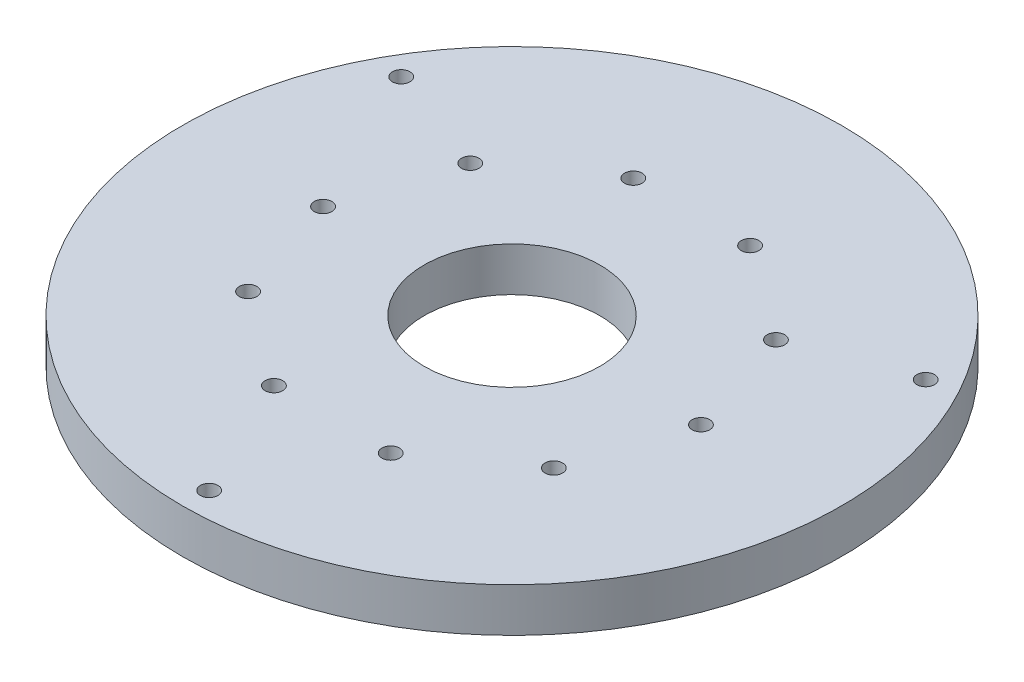
from build123d import *

# Parameters (mm, degrees)
SKETCH1_R           = 37.5
BOSS_EXTRUDE1_DEPTH = 5
CUT_EXTRUDE1_REACH  = 7
SKETCH2_R           = 1
CUT_EXTRUDE2_DEPTH  = 1.6
CUT_EXTRUDE3_REACH  = 7
SKETCH6_R           = 10
SKETCH7_R           = 1
CUT_EXTRUDE4_DEPTH  = 5


with BuildPart() as part:
    # Sketch1 → Boss-Extrude1 (new body)
    with BuildSketch(Plane(origin=(0, 0, 0), x_dir=(1, 0, 0), z_dir=(0, 1, 0))):
        Circle(SKETCH1_R)
    extrude(amount=-BOSS_EXTRUDE1_DEPTH)

    # Sketch2 → Cut-Extrude1 (cut, up to next)
    with BuildSketch(Plane(origin=(0, 0, 0), x_dir=(1, 0, 0), z_dir=(0, 1, 0)), mode=Mode.PRIVATE) as cut_extrude1_sk1:
        with Locations((-21.5, 0)):
            Circle(SKETCH2_R)
    cut_extrude1_tool1 = extrude(cut_extrude1_sk1.sketch, amount=-CUT_EXTRUDE1_REACH, mode=Mode.PRIVATE) & part.part
    add(cut_extrude1_tool1.solids().sort_by_distance((-21.5, 0, 0))[0], mode=Mode.SUBTRACT)
    # Sketch2 → Cut-Extrude1 (cut, up to next)
    with BuildSketch(Plane(origin=(0, 0, 0), x_dir=(1, 0, 0), z_dir=(0, 1, 0)), mode=Mode.PRIVATE) as cut_extrude1_sk2:
        with Locations((-17.393865379, 12.637382924)):
            Circle(SKETCH2_R)
    cut_extrude1_tool2 = extrude(cut_extrude1_sk2.sketch, amount=-CUT_EXTRUDE1_REACH, mode=Mode.PRIVATE) & part.part
    add(cut_extrude1_tool2.solids().sort_by_distance((-17.393865, 0, -12.637383))[0], mode=Mode.SUBTRACT)
    # Sketch2 → Cut-Extrude1 (cut, up to next)
    with BuildSketch(Plane(origin=(0, 0, 0), x_dir=(1, 0, 0), z_dir=(0, 1, 0)), mode=Mode.PRIVATE) as cut_extrude1_sk3:
        with Locations((-6.643865379, 20.4477151)):
            Circle(SKETCH2_R)
    cut_extrude1_tool3 = extrude(cut_extrude1_sk3.sketch, amount=-CUT_EXTRUDE1_REACH, mode=Mode.PRIVATE) & part.part
    add(cut_extrude1_tool3.solids().sort_by_distance((-6.643865, 0, -20.447715))[0], mode=Mode.SUBTRACT)
    # Sketch2 → Cut-Extrude1 (cut, up to next)
    with BuildSketch(Plane(origin=(0, 0, 0), x_dir=(1, 0, 0), z_dir=(0, 1, 0)), mode=Mode.PRIVATE) as cut_extrude1_sk4:
        with Locations((6.643865379, 20.4477151)):
            Circle(SKETCH2_R)
    cut_extrude1_tool4 = extrude(cut_extrude1_sk4.sketch, amount=-CUT_EXTRUDE1_REACH, mode=Mode.PRIVATE) & part.part
    add(cut_extrude1_tool4.solids().sort_by_distance((6.643865, 0, -20.447715))[0], mode=Mode.SUBTRACT)
    # Sketch2 → Cut-Extrude1 (cut, up to next)
    with BuildSketch(Plane(origin=(0, 0, 0), x_dir=(1, 0, 0), z_dir=(0, 1, 0)), mode=Mode.PRIVATE) as cut_extrude1_sk5:
        with Locations((17.393865379, 12.637382924)):
            Circle(SKETCH2_R)
    cut_extrude1_tool5 = extrude(cut_extrude1_sk5.sketch, amount=-CUT_EXTRUDE1_REACH, mode=Mode.PRIVATE) & part.part
    add(cut_extrude1_tool5.solids().sort_by_distance((17.393865, 0, -12.637383))[0], mode=Mode.SUBTRACT)
    # Sketch2 → Cut-Extrude1 (cut, up to next)
    with BuildSketch(Plane(origin=(0, 0, 0), x_dir=(1, 0, 0), z_dir=(0, 1, 0)), mode=Mode.PRIVATE) as cut_extrude1_sk6:
        with Locations((21.5, 0)):
            Circle(SKETCH2_R)
    cut_extrude1_tool6 = extrude(cut_extrude1_sk6.sketch, amount=-CUT_EXTRUDE1_REACH, mode=Mode.PRIVATE) & part.part
    add(cut_extrude1_tool6.solids().sort_by_distance((21.5, 0, 0))[0], mode=Mode.SUBTRACT)
    # Sketch2 → Cut-Extrude1 (cut, up to next)
    with BuildSketch(Plane(origin=(0, 0, 0), x_dir=(1, 0, 0), z_dir=(0, 1, 0)), mode=Mode.PRIVATE) as cut_extrude1_sk7:
        with Locations((17.393865379, -12.637382924)):
            Circle(SKETCH2_R)
    cut_extrude1_tool7 = extrude(cut_extrude1_sk7.sketch, amount=-CUT_EXTRUDE1_REACH, mode=Mode.PRIVATE) & part.part
    add(cut_extrude1_tool7.solids().sort_by_distance((17.393865, 0, 12.637383))[0], mode=Mode.SUBTRACT)
    # Sketch2 → Cut-Extrude1 (cut, up to next)
    with BuildSketch(Plane(origin=(0, 0, 0), x_dir=(1, 0, 0), z_dir=(0, 1, 0)), mode=Mode.PRIVATE) as cut_extrude1_sk8:
        with Locations((6.643865379, -20.4477151)):
            Circle(SKETCH2_R)
    cut_extrude1_tool8 = extrude(cut_extrude1_sk8.sketch, amount=-CUT_EXTRUDE1_REACH, mode=Mode.PRIVATE) & part.part
    add(cut_extrude1_tool8.solids().sort_by_distance((6.643865, 0, 20.447715))[0], mode=Mode.SUBTRACT)
    # Sketch2 → Cut-Extrude1 (cut, up to next)
    with BuildSketch(Plane(origin=(0, 0, 0), x_dir=(1, 0, 0), z_dir=(0, 1, 0)), mode=Mode.PRIVATE) as cut_extrude1_sk9:
        with Locations((-6.643865379, -20.4477151)):
            Circle(SKETCH2_R)
    cut_extrude1_tool9 = extrude(cut_extrude1_sk9.sketch, amount=-CUT_EXTRUDE1_REACH, mode=Mode.PRIVATE) & part.part
    add(cut_extrude1_tool9.solids().sort_by_distance((-6.643865, 0, 20.447715))[0], mode=Mode.SUBTRACT)
    # Sketch2 → Cut-Extrude1 (cut, up to next)
    with BuildSketch(Plane(origin=(0, 0, 0), x_dir=(1, 0, 0), z_dir=(0, 1, 0)), mode=Mode.PRIVATE) as cut_extrude1_sk10:
        with Locations((-17.393865379, -12.637382924)):
            Circle(SKETCH2_R)
    cut_extrude1_tool10 = extrude(cut_extrude1_sk10.sketch, amount=-CUT_EXTRUDE1_REACH, mode=Mode.PRIVATE) & part.part
    add(cut_extrude1_tool10.solids().sort_by_distance((-17.393865, 0, 12.637383))[0], mode=Mode.SUBTRACT)

    # Sketch4 → Cut-Extrude2 (cut)
    with BuildSketch(Plane.XZ.offset(5)):
        Polygon((-15.525520661, 11.27995103), (-15.284122516, 13.576700966), (-17.152467233, 14.93413286), (-19.262210097, 13.994814819), (-19.503608243, 11.698064883), (-17.635263525, 10.340632988), align=None)
        Polygon((-19.190598923, 0), (-20.345299462, 2), (-22.654700538, 2), (-23.809401077, 0), (-22.654700538, -2), (-20.345299462, -2), align=None)
        Polygon((-5.9302212, 18.251344158), (-4.384930257, 19.967563618), (-5.098574436, 22.16393456), (-7.357509559, 22.644086043), (-8.902800501, 20.927866583), (-8.189156322, 18.73149564), align=None)
        Polygon((5.9302212, 18.251344158), (8.189156322, 18.73149564), (8.902800501, 20.927866583), (7.357509559, 22.644086043), (5.098574436, 22.16393456), (4.384930257, 19.967563618), align=None)
        Polygon((15.525520661, 11.27995103), (17.635263525, 10.340632988), (19.503608243, 11.698064883), (19.262210097, 13.994814819), (17.152467233, 14.93413286), (15.284122516, 13.576700966), align=None)
        Polygon((19.190598923, 0), (20.345299462, -2), (22.654700538, -2), (23.809401077, 0), (22.654700538, 2), (20.345299462, 2), align=None)
        Polygon((15.525520661, -11.27995103), (15.284122516, -13.576700966), (17.152467233, -14.93413286), (19.262210097, -13.994814819), (19.503608243, -11.698064883), (17.635263525, -10.340632988), align=None)
        Polygon((5.9302212, -18.251344158), (4.384930257, -19.967563618), (5.098574436, -22.16393456), (7.357509559, -22.644086043), (8.902800501, -20.927866583), (8.189156322, -18.73149564), align=None)
        Polygon((-5.9302212, -18.251344158), (-8.189156322, -18.73149564), (-8.902800501, -20.927866583), (-7.357509559, -22.644086043), (-5.098574436, -22.16393456), (-4.384930257, -19.967563618), align=None)
        Polygon((-15.525520661, -11.27995103), (-17.635263525, -10.340632988), (-19.503608243, -11.698064883), (-19.262210097, -13.994814819), (-17.152467233, -14.93413286), (-15.284122516, -13.576700966), align=None)
    extrude(amount=-CUT_EXTRUDE2_DEPTH, mode=Mode.SUBTRACT)

    # Sketch6 → Cut-Extrude3 (cut, up to next)
    with BuildSketch(Plane(origin=(0, 0, 0), x_dir=(1, 0, 0), z_dir=(0, 1, 0)), mode=Mode.PRIVATE) as cut_extrude3_sk1:
        Circle(SKETCH6_R)
    cut_extrude3_tool1 = extrude(cut_extrude3_sk1.sketch, amount=-CUT_EXTRUDE3_REACH, mode=Mode.PRIVATE) & part.part
    add(cut_extrude3_tool1.solids().sort_by_distance((0, 0, 0))[0], mode=Mode.SUBTRACT)

    # Sketch7 → Cut-Extrude4 (cut)
    with BuildSketch(Plane(origin=(0, 0, 0), x_dir=(1, 0, 0), z_dir=(0, 1, 0))):
        with Locations((0, -34.458998708)):
            Circle(SKETCH7_R)
        with Locations((-29.84236827, 17.229499354)):
            Circle(SKETCH7_R)
        with Locations((29.84236827, 17.229499354)):
            Circle(SKETCH7_R)
    extrude(amount=-CUT_EXTRUDE4_DEPTH, mode=Mode.SUBTRACT)


solid = part.part
